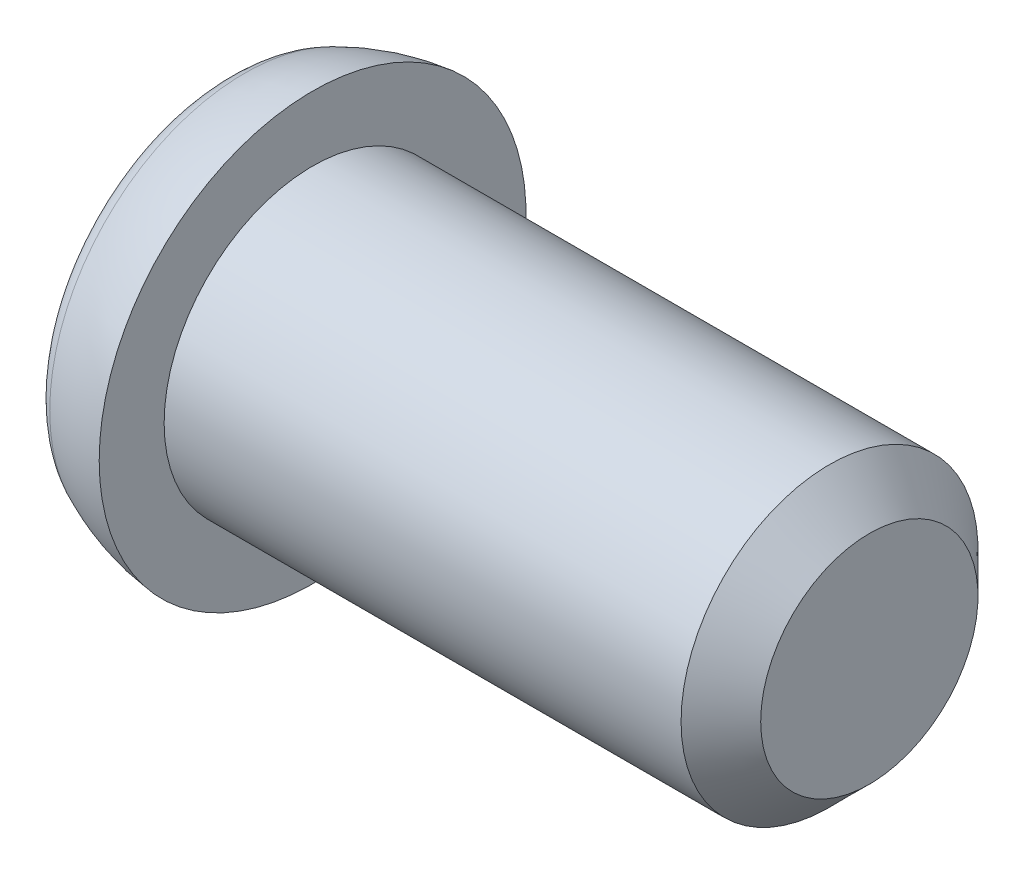
from build123d import *

# Parameters (mm, degrees)
CUT_EXTRUDE1_DEPTH      = 0.115
CUT_EXTRUDE1_DEPTH_BACK = 0.115
CUT_EXTRUDE2_DEPTH      = 0.115
CUT_EXTRUDE2_DEPTH_BACK = 0.115


with BuildPart() as part:
    # Sketch1 → Revolve1 (revolve)
    with BuildSketch(Plane.XY):
        with BuildLine():
            Line((-0.5, 0), (-0.5, 0.84133137))
            ThreePointArc((-0.5, 0.84133137), (-0.463697933, 0.965351975), (-0.366251212, 1.050222978))
            ThreePointArc((-0.366251212, 1.050222978), (-0.187270905, 1.115327627), (0, 1.15))
            Line((0, 1.15), (0, 0.8))
            Line((0, 0.8), (2.7855, 0.8))
            Line((2.7855, 0.8), (3, 0.5855))
            Line((3, 0.5855), (3, 0))
            Line((3, 0), (-0.5, 0))
        make_face()
    revolve(axis=Axis((3, 0, 0), (-1, 0, 0)))

    # Sketch2 → Cut-Extrude1 (cut, two sides: drawn at the far end of the back side and taken through both)
    with BuildSketch(Plane.XY.offset(-CUT_EXTRUDE1_DEPTH_BACK)):
        with BuildLine():
            Line((-0.5, 0.575), (-0.5, -0.575))
            ThreePointArc((-0.5, -0.575), (-0.07432444, -0.379626768), (0.2, 0))
            ThreePointArc((0.2, 0), (-0.07432444, 0.379626768), (-0.5, 0.575))
        make_face()
    extrude(amount=CUT_EXTRUDE1_DEPTH + CUT_EXTRUDE1_DEPTH_BACK, mode=Mode.SUBTRACT)

    # Sketch3 → Cut-Extrude2 (cut, two sides: drawn at the far end of the back side and taken through both)
    with BuildSketch(Plane(origin=(0, 0, 0), x_dir=(1, 0, 0), z_dir=(0, 1, 0)).offset(-CUT_EXTRUDE2_DEPTH_BACK)):
        with BuildLine():
            Line((-0.5, 0.575), (-0.5, -0.575))
            ThreePointArc((-0.5, -0.575), (-0.07432444, -0.379626768), (0.2, 0))
            ThreePointArc((0.2, 0), (-0.07432444, 0.379626768), (-0.5, 0.575))
        make_face()
    extrude(amount=CUT_EXTRUDE2_DEPTH + CUT_EXTRUDE2_DEPTH_BACK, mode=Mode.SUBTRACT)


solid = part.part
